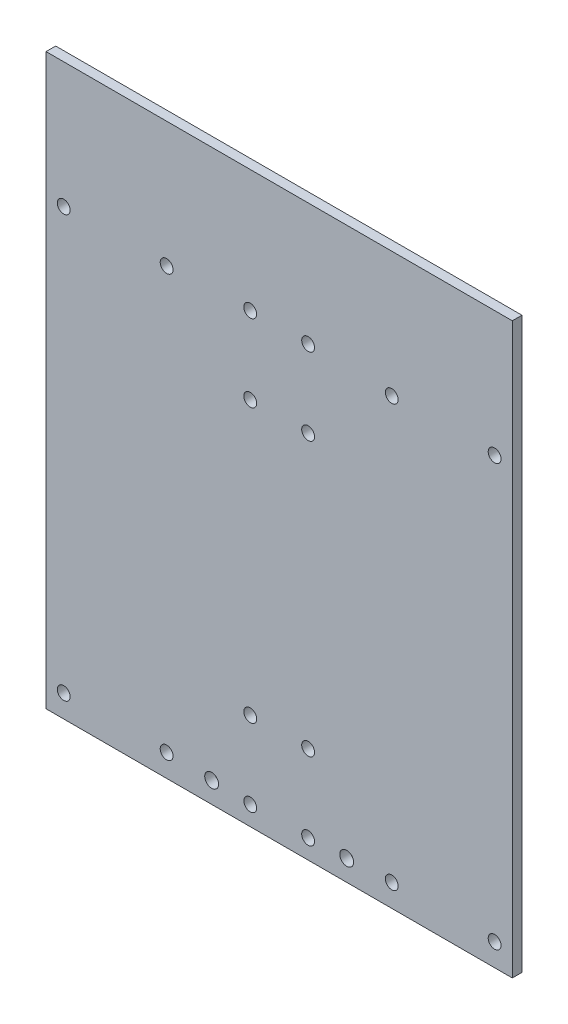
from build123d import *

# Parameters (mm, degrees)
SKETCH1_R           = 2
SKETCH1_R_2         = 2.162090294
BOSS_EXTRUDE1_DEPTH = 3


with BuildPart() as part:
    # Sketch1 → Boss-Extrude1 (new body)
    with BuildSketch(Plane.XY):
        Polygon((72.5, 104.5), (-72.5, 104.5), (-72.5, 72.5), (-72.5, -72.5), (72.5, -72.5), (72.5, 72.5), align=None)
        with Locations((67, 65.5)):
            Circle(SKETCH1_R, mode=Mode.SUBTRACT)
        with Locations((-35, 65.5)):
            Circle(SKETCH1_R, mode=Mode.SUBTRACT)
        with Locations((-67, 65.5)):
            Circle(SKETCH1_R, mode=Mode.SUBTRACT)
        with Locations((-67, -65.5)):
            Circle(SKETCH1_R, mode=Mode.SUBTRACT)
        with Locations((67, -65.5)):
            Circle(SKETCH1_R, mode=Mode.SUBTRACT)
        with Locations((35, -65.5)):
            Circle(SKETCH1_R, mode=Mode.SUBTRACT)
        with Locations((21, -66)):
            Circle(SKETCH1_R_2, mode=Mode.SUBTRACT)
        with Locations((-21, -66)):
            Circle(SKETCH1_R_2, mode=Mode.SUBTRACT)
        with Locations((-9, -42.5)):
            Circle(SKETCH1_R, mode=Mode.SUBTRACT)
        with Locations((9, -66.5)):
            Circle(SKETCH1_R, mode=Mode.SUBTRACT)
        with Locations((9, 66.5)):
            Circle(SKETCH1_R, mode=Mode.SUBTRACT)
        with Locations((-9, 66.5)):
            Circle(SKETCH1_R, mode=Mode.SUBTRACT)
        with Locations((-9, 42.5)):
            Circle(SKETCH1_R, mode=Mode.SUBTRACT)
        with Locations((9, 42.5)):
            Circle(SKETCH1_R, mode=Mode.SUBTRACT)
        with Locations((-9, -66.5)):
            Circle(SKETCH1_R, mode=Mode.SUBTRACT)
        with Locations((9, -42.5)):
            Circle(SKETCH1_R, mode=Mode.SUBTRACT)
        with Locations((-35, -65.5)):
            Circle(SKETCH1_R, mode=Mode.SUBTRACT)
        with Locations((35, 65.5)):
            Circle(SKETCH1_R, mode=Mode.SUBTRACT)
    extrude(amount=BOSS_EXTRUDE1_DEPTH)


solid = part.part
